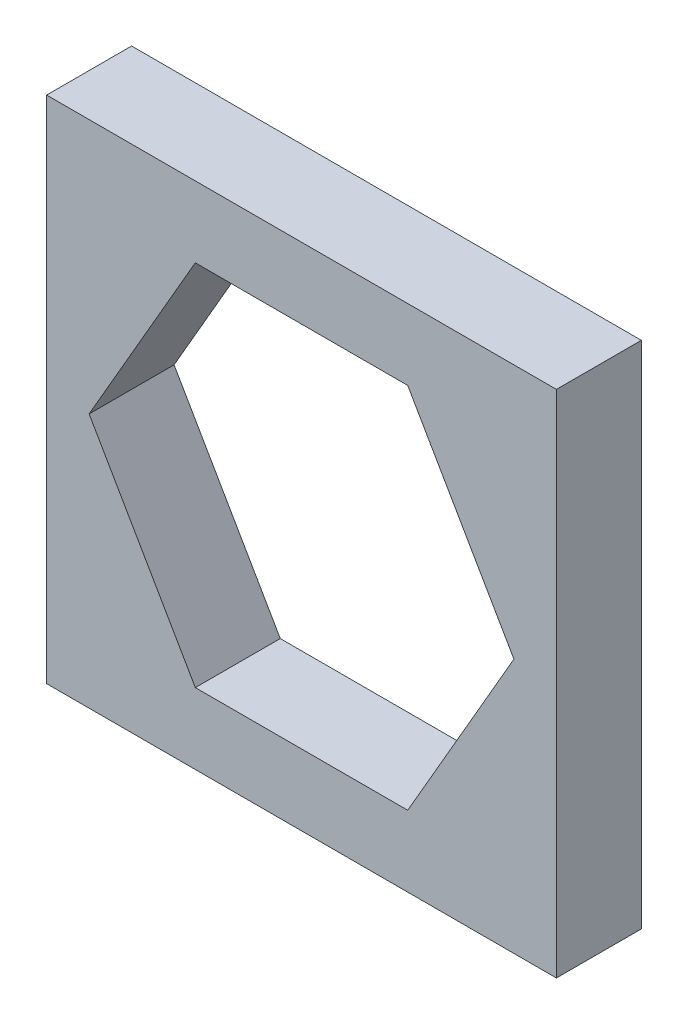
from build123d import *

# Parameters (mm, degrees)
SCHIZZO1_W                   = 60
SCHIZZO1_H                   = 60
ESTRUSIONE_ESTRUSIONE1_DEPTH = 10


with BuildPart() as part:
    # Schizzo1 → Estrusione-Estrusione1 (new body)
    with BuildSketch(Plane.XY):
        Rectangle(SCHIZZO1_W, SCHIZZO1_H)
        Polygon((12.5, -21.650635095), (25, 0), (12.5, 21.650635095), (-12.5, 21.650635095), (-25, 0), (-12.5, -21.650635095), align=None, mode=Mode.SUBTRACT)
    extrude(amount=ESTRUSIONE_ESTRUSIONE1_DEPTH)


solid = part.part
